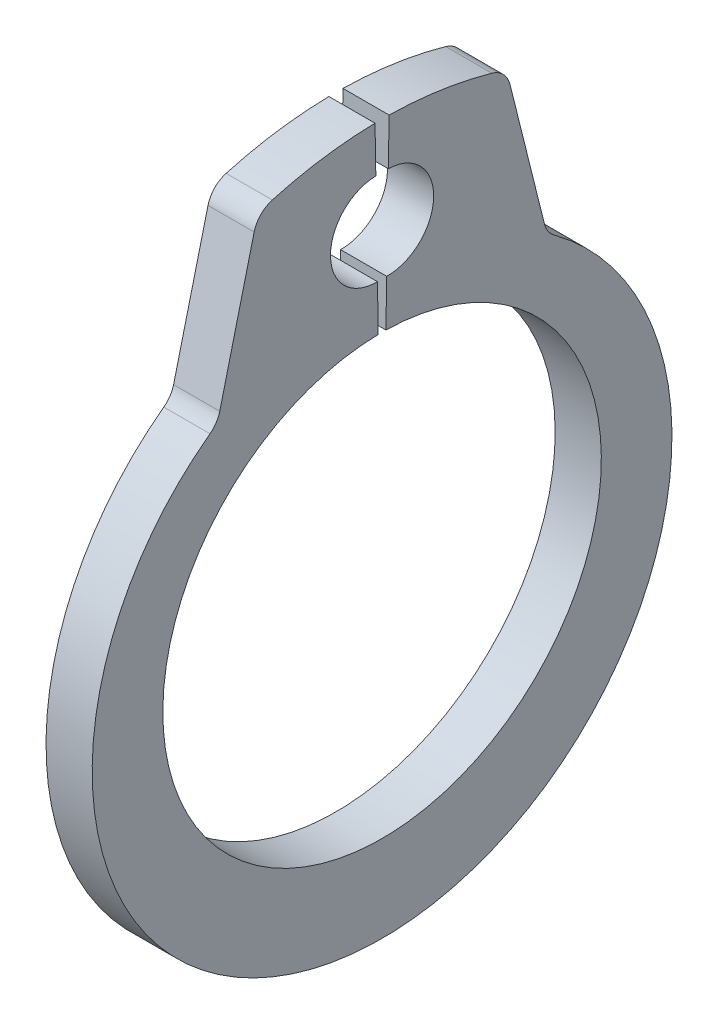
from build123d import *

# Parameters (mm, degrees)
EXTRUDE1_DEPTH = 0.4
FILLET1_R      = 0.45


with BuildPart() as part:
    # Sketch1 → Extrude1 (new body, symmetric)
    with BuildSketch(Plane(origin=(0, 0, 0), x_dir=(0, 0, -1), z_dir=(1, 0, 0))):
        with BuildLine():
            Line((0.066319144, 3.799421242), (0.08028107, 4.599299398))
            ThreePointArc((0.08028107, 4.599299398), (0.894121151, 5.385215629), (0.10820492, 6.19905571))
            Line((0.10820492, 6.19905571), (0.122166845, 6.998933866))
            ThreePointArc((0.122166845, 6.998933866), (1.151239086, 6.904683089), (2.155222001, 6.659956316))
            Line((2.155222001, 6.659956316), (2.853372649, 3.859827007))
            ThreePointArc((2.853372649, 3.859827007), (0, -5.3), (-2.853372649, 3.859827007))
            Line((-2.853372649, 3.859827007), (-2.155222001, 6.659956316))
            ThreePointArc((-2.155222001, 6.659956316), (-1.151239086, 6.904683089), (-0.122166845, 6.998933866))
            Line((-0.122166845, 6.998933866), (-0.10820492, 6.19905571))
            ThreePointArc((-0.10820492, 6.19905571), (-0.894121151, 5.385215629), (-0.08028107, 4.599299398))
            Line((-0.08028107, 4.599299398), (-0.066319144, 3.799421242))
            ThreePointArc((-0.066319144, 3.799421242), (0, -3.8), (0.066319144, 3.799421242))
        make_face()
    extrude(amount=EXTRUDE1_DEPTH, both=True)

    # Fillet1
    fillet1_edges = [part.edges().sort_by_distance(p)[0] for p in [
        (0, 6.659956316, -2.155222001),
        (0, 3.859827007, -2.853372649),
        (0, 3.859827007, 2.853372649),
        (0, 6.659956316, 2.155222001),
    ]]
    fillet(fillet1_edges, radius=FILLET1_R)


solid = part.part
